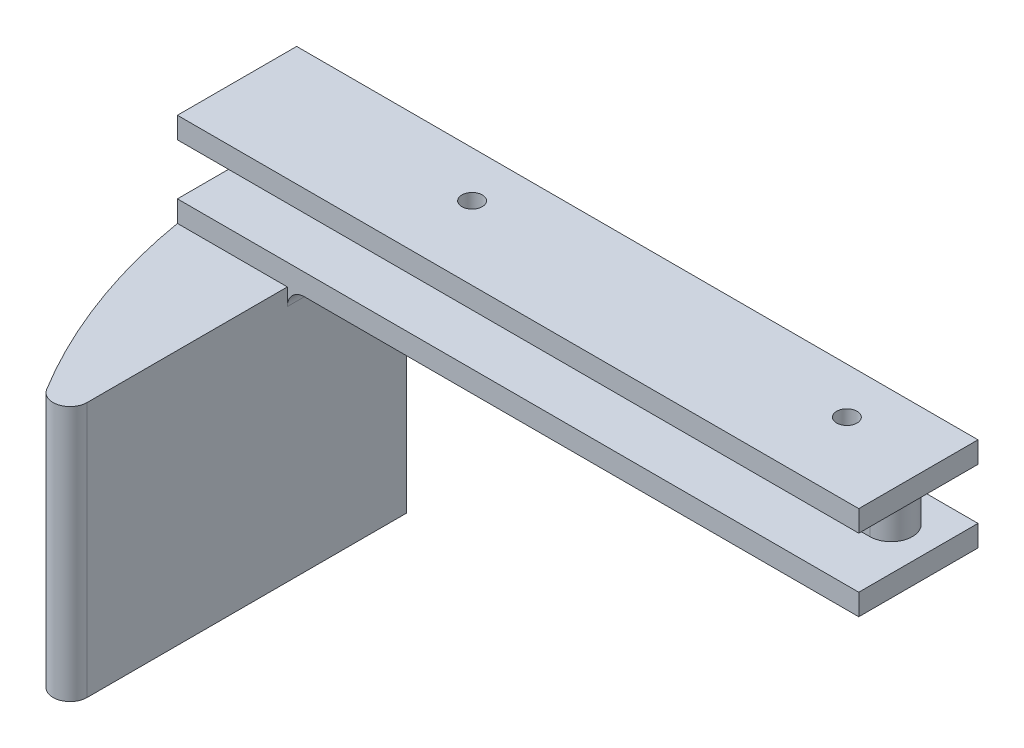
from build123d import *

# Parameters (mm, degrees)
SKETCH2_W           = 101.6
SKETCH2_H           = 17.78
BOSS_EXTRUDE1_DEPTH = 3.175
BOSS_EXTRUDE2_DEPTH = 7.62
BOSS_EXTRUDE3_DEPTH = 38.1
FILLET1_R           = 2.54
FILLET2_R           = 2.54
SKETCH5_R           = 1.524
CUT_EXTRUDE1_DEPTH  = 14.97


with BuildPart() as part:
    # Sketch2 → Boss-Extrude1 (new body)
    with BuildSketch(Plane(origin=(0, 0, 0), x_dir=(1, 0, 0), z_dir=(0, 1, 0))):
        with Locations((50.8, 8.89)):
            Rectangle(SKETCH2_W, SKETCH2_H)
    boss_extrude1 = extrude(amount=BOSS_EXTRUDE1_DEPTH)

    # Sketch3 → Boss-Extrude2 (add)
    with BuildSketch(Plane.XZ):
        with BuildLine():
            Line((95.25, -14.351), (6.35, -14.351))
            ThreePointArc((6.35, -14.351), (3.175, -11.176), (6.35, -8.001))
            Line((6.35, -8.001), (95.25, -8.001))
            ThreePointArc((95.25, -8.001), (98.425, -11.176), (95.25, -14.351))
        make_face()
    extrude(amount=BOSS_EXTRUDE2_DEPTH)

    # Mirror1: Boss-Extrude1 across plane
    add(boss_extrude1.mirror(Plane(origin=(0, -3.81, 0), x_dir=(0, 0, 1), z_dir=(0, -1, 0))))

    # Sketch4 → Boss-Extrude3 (add)
    with BuildSketch(Plane.XZ.offset(10.795)):
        with BuildLine():
            Line((0, -17.78), (16.393849753, -17.78))
            Line((16.393849753, -17.78), (16.393849753, 0))
            Line((16.393849753, 0), (16.393849753, 38.1))
            ThreePointArc((16.393849753, 38.1), (5.909394782, 20.034289362), (0, 0))
            Line((0, 0), (0, -17.78))
        make_face()
    extrude(amount=BOSS_EXTRUDE3_DEPTH)

    # Fillet1
    fillet1_edges = [part.edges().sort_by_distance(p)[0] for p in [
        (16.393849753, -10.795, -8.89),
    ]]
    fillet(fillet1_edges, radius=FILLET1_R)

    # Fillet2
    fillet2_edges = [part.edges().sort_by_distance(p)[0] for p in [
        (16.393849753, -29.845, 38.1),
    ]]
    fillet(fillet2_edges, radius=FILLET2_R)

    # Sketch5 → Cut-Extrude1 (cut, through all)
    with BuildSketch(Plane(origin=(0, -10.795, 0), x_dir=(-1, 0, 0), z_dir=(0, -1, 0))):
        with Locations((-88.9, 10.922)):
            Circle(SKETCH5_R)
        with Locations((-33.02, 10.922)):
            Circle(SKETCH5_R)
    extrude(amount=-CUT_EXTRUDE1_DEPTH, mode=Mode.SUBTRACT)


solid = part.part
